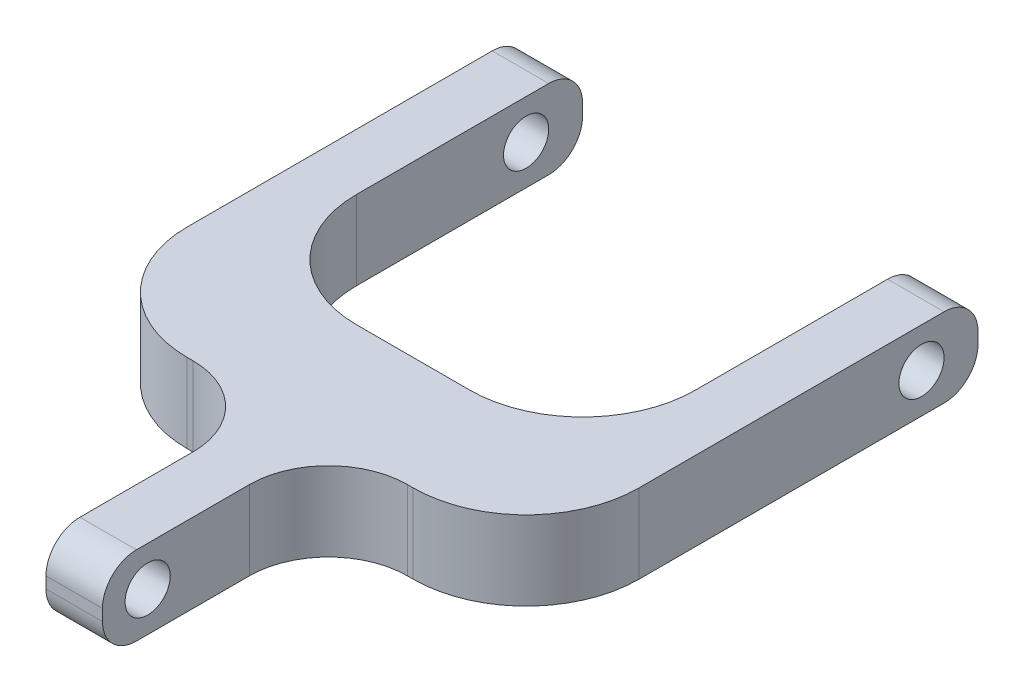
from build123d import *

# Parameters (mm, degrees)
SKETCH1_W           = 40
SKETCH1_H           = 7
BOSS_EXTRUDE1_DEPTH = 40
CUT_EXTRUDE1_DEPTH  = 8
FILLET1_R           = 10
SKETCH5_W           = 5
SKETCH5_H           = 7
BOSS_EXTRUDE2_DEPTH = 20
FILLET2_R           = 7
FILLET3_R           = 3
SKETCH6_R           = 2
CUT_EXTRUDE2_DEPTH  = 41
SKETCH7_R           = 2
CUT_EXTRUDE3_DEPTH  = 23.5


with BuildPart() as part:
    # Sketch1 → Boss-Extrude1 (new body)
    with BuildSketch(Plane(origin=(0, 0, 0), x_dir=(0, 0, -1), z_dir=(1, 0, 0))):
        Rectangle(SKETCH1_W, SKETCH1_H)
    extrude(amount=BOSS_EXTRUDE1_DEPTH)

    # Sketch2 → Cut-Extrude1 (cut, through all)
    with BuildSketch(Plane(origin=(0, 3.5, 0), x_dir=(1, 0, 0), z_dir=(0, 1, 0))):
        with BuildLine():
            Line((5, 20), (35, 20))
            Line((35, 20), (35, 0))
            ThreePointArc((35, 0), (32.071067812, -7.071067812), (25, -10))
            Line((25, -10), (15, -10))
            ThreePointArc((15, -10), (7.928932188, -7.071067812), (5, 0))
            Line((5, 0), (5, 20))
        make_face()
    extrude(amount=-CUT_EXTRUDE1_DEPTH, mode=Mode.SUBTRACT)

    # Fillet1
    fillet1_edges = [part.edges().sort_by_distance(p)[0] for p in [
        (40, 0, 20),
        (0, 0, 20),
    ]]
    fillet(fillet1_edges, radius=FILLET1_R)

    # Sketch5 → Boss-Extrude2 (add)
    with BuildSketch(Plane.XY.offset(20)):
        with Locations((20, 0)):
            Rectangle(SKETCH5_W, SKETCH5_H)
    extrude(amount=BOSS_EXTRUDE2_DEPTH)

    # Fillet2
    fillet2_edges = [part.edges().sort_by_distance(p)[0] for p in [
        (17.5, 0, 20),
        (22.5, 0, 20),
    ]]
    fillet(fillet2_edges, radius=FILLET2_R)

    # Fillet3
    fillet3_edges = [part.edges().sort_by_distance(p)[0] for p in [
        (2.5, -3.5, -20),
        (2.5, 3.5, -20),
        (20, -3.5, 40),
        (20, 3.5, 40),
        (37.5, -3.5, -20),
        (37.5, 3.5, -20),
    ]]
    fillet(fillet3_edges, radius=FILLET3_R)

    # Sketch6 → Cut-Extrude2 (cut, through all)
    with BuildSketch(Plane(origin=(40, 0, 0), x_dir=(0, 0, -1), z_dir=(1, 0, 0))):
        with Locations((15, 0)):
            Circle(SKETCH6_R)
    extrude(amount=-CUT_EXTRUDE2_DEPTH, mode=Mode.SUBTRACT)

    # Sketch7 → Cut-Extrude3 (cut, through all)
    with BuildSketch(Plane(origin=(22.5, 0, 0), x_dir=(0, 0, -1), z_dir=(1, 0, 0))):
        with Locations((-36, 0)):
            Circle(SKETCH7_R)
    extrude(amount=-CUT_EXTRUDE3_DEPTH, mode=Mode.SUBTRACT)


solid = part.part
